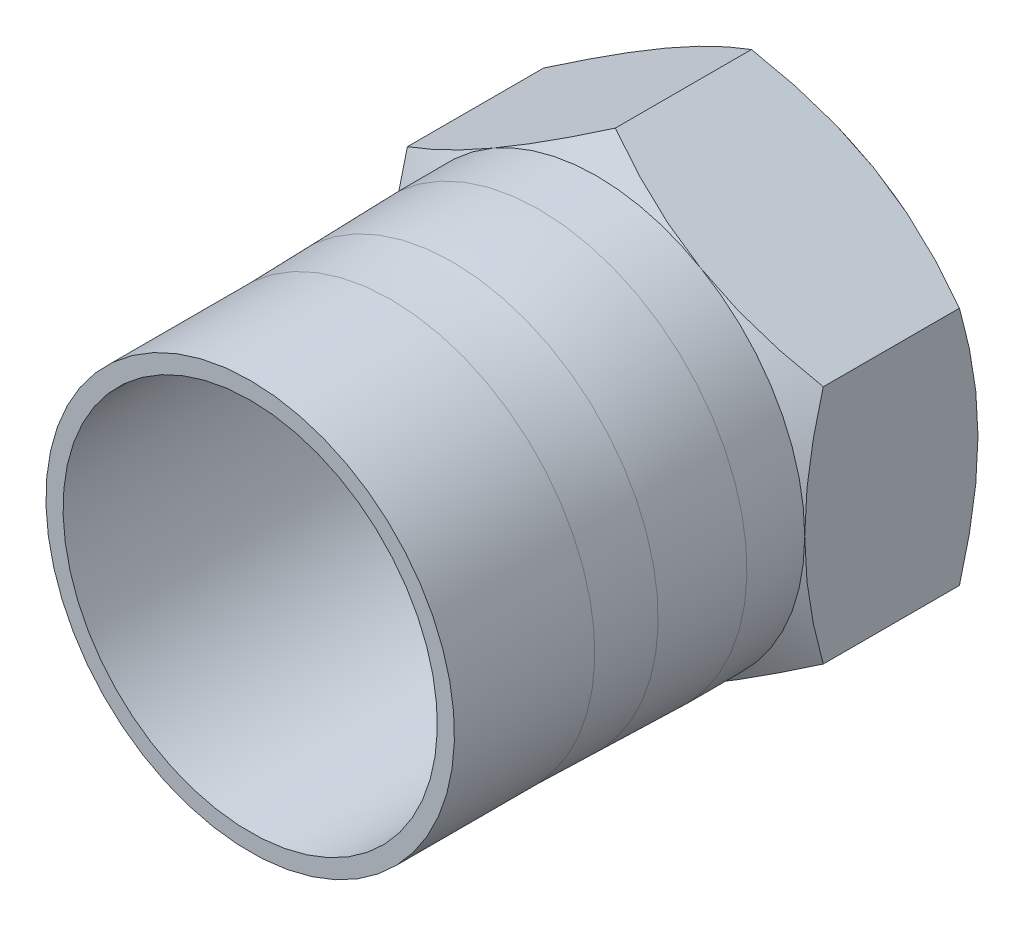
from build123d import *

# Parameters (mm, degrees)
BOSS_EXTRUDE1_DEPTH      = 23.01875
BOSS_EXTRUDE1_DEPTH_BACK = 16.66875
SKETCH8_OUTSIDE_W        = 7085.338
SKETCH8_OUTSIDE_H        = 7090.25
SKETCH8_OUTSIDE_R        = 15.875
CUT_EXTRUDE7_DEPTH       = 2032
CUT_EXTRUDE7_TAPER       = 60
SKETCH20_OUTSIDE_W       = 55.082
SKETCH20_OUTSIDE_H       = 59.994
SKETCH20_OUTSIDE_R       = 15.875
CUT_EXTRUDE9_DEPTH       = 2.54
CUT_EXTRUDE9_TAPER       = 60
CHAMFER1_SIZE2           = 1.101615862
CHAMFER1_SIZE            = 1.0668


with BuildPart() as part:
    # Sketch2 → Boss-Extrude1 (new body, two sides)
    with BuildSketch(Plane.XY) as boss_extrude1_sk:
        Polygon((0, 18.330871047), (-15.875, 9.165435523), (-15.875, -9.165435523), (0, -18.330871047), (15.875, -9.165435523), (15.875, 9.165435523), align=None)
    extrude(amount=BOSS_EXTRUDE1_DEPTH)
    extrude(boss_extrude1_sk.sketch, amount=-BOSS_EXTRUDE1_DEPTH_BACK)

    # Sketch5 → Cut-Revolve1 (revolve, cut)
    with BuildSketch(Plane(origin=(0, 0, 0), x_dir=(0, 0, -1), z_dir=(1, 0, 0))):
        Polygon((-23.01875, 0), (-23.01875, 14.2875), (0, 14.2875), (1.918229167, 11.43), (3.836458333, 11.43), (5.580126, 12.989754658), (16.66875, 13.335), (16.66875, 0), align=None)
    revolve(axis=Axis((0, 0, -16.66875), (0, 0, 1)), mode=Mode.SUBTRACT)

    # Sketch24 → Cut-Revolve2 (revolve, cut)
    with BuildSketch(Plane(origin=(0, 0, 0), x_dir=(0, 0, -1), z_dir=(1, 0, 0))):
        with BuildLine():
            Line((-23.01875, 15.5956), (-23.01875, 18.330871047))
            Line((-23.01875, 18.330871047), (3.439583333, 18.330871047))
            Line((3.439583333, 18.330871047), (3.439583333, 15.875))
            Line((3.439583333, 15.875), (-0.970138889, 15.875))
            ThreePointArc((-0.970138889, 15.875), (-4.278435497, 15.834225325), (-7.584722222, 15.71192607))
            ThreePointArc((-7.584722222, 15.71192607), (-9.943206753, 15.624685935), (-12.303125, 15.5956))
            Line((-12.303125, 15.5956), (-23.01875, 15.5956))
        make_face()
    revolve(axis=Axis((0, 0, 0), (0, 0, 1)), mode=Mode.SUBTRACT)

    # Sketch8 outside → Cut-Extrude7 (cut)
    with BuildSketch(Plane.XY.offset(-16.66875)):
        Rectangle(SKETCH8_OUTSIDE_W, SKETCH8_OUTSIDE_H)
        Circle(SKETCH8_OUTSIDE_R, mode=Mode.SUBTRACT)
    extrude(amount=CUT_EXTRUDE7_DEPTH, taper=CUT_EXTRUDE7_TAPER, mode=Mode.SUBTRACT)

    # Sketch20 outside → Cut-Extrude9 (cut)
    with BuildSketch(Plane(origin=(0, 0, -3.439583333), x_dir=(-1, 0, 0), z_dir=(0, 0, -1))):
        Rectangle(SKETCH20_OUTSIDE_W, SKETCH20_OUTSIDE_H)
        Circle(SKETCH20_OUTSIDE_R, mode=Mode.SUBTRACT)
    extrude(amount=CUT_EXTRUDE9_DEPTH, taper=CUT_EXTRUDE9_TAPER, mode=Mode.SUBTRACT)

    # Chamfer1
    chamfer1_edges = [part.edges().sort_by_distance(p)[0] for p in [
        (0, -13.335, -16.66875),
    ]]
    chamfer(chamfer1_edges, length=CHAMFER1_SIZE, length2=CHAMFER1_SIZE2)


solid = part.part
